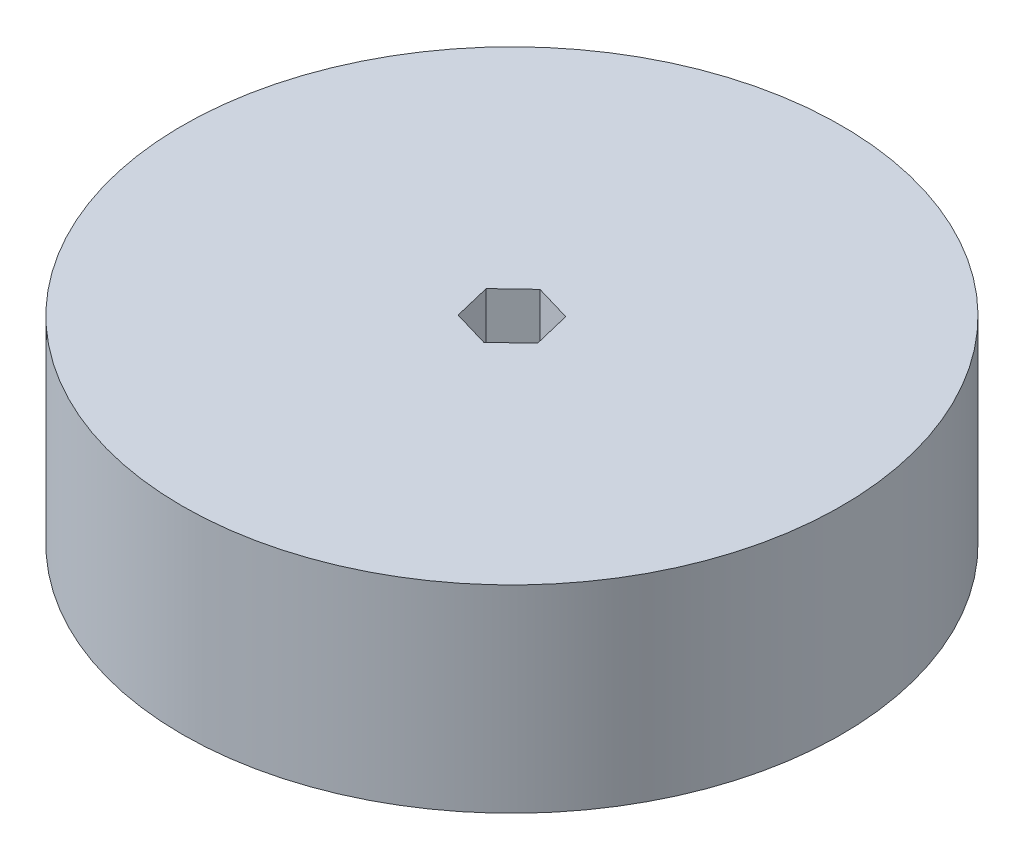
from build123d import *

# Parameters (mm, degrees)
SKETCH1_R           = 63.5
BOSS_EXTRUDE1_DEPTH = 19.05


with BuildPart() as part:
    # Sketch1 → Boss-Extrude1 (new body, symmetric)
    with BuildSketch(Plane(origin=(0, 0, 0), x_dir=(1, 0, 0), z_dir=(0, 1, 0))):
        Circle(SKETCH1_R)
        Polygon((-7.033264454, 2.072805937), (-5.311734826, -5.05458272), (1.721529628, -7.127388657), (7.033264454, -2.072805937), (5.311734826, 5.05458272), (-1.721529628, 7.127388657), align=None, mode=Mode.SUBTRACT)
    extrude(amount=BOSS_EXTRUDE1_DEPTH, both=True)


solid = part.part
